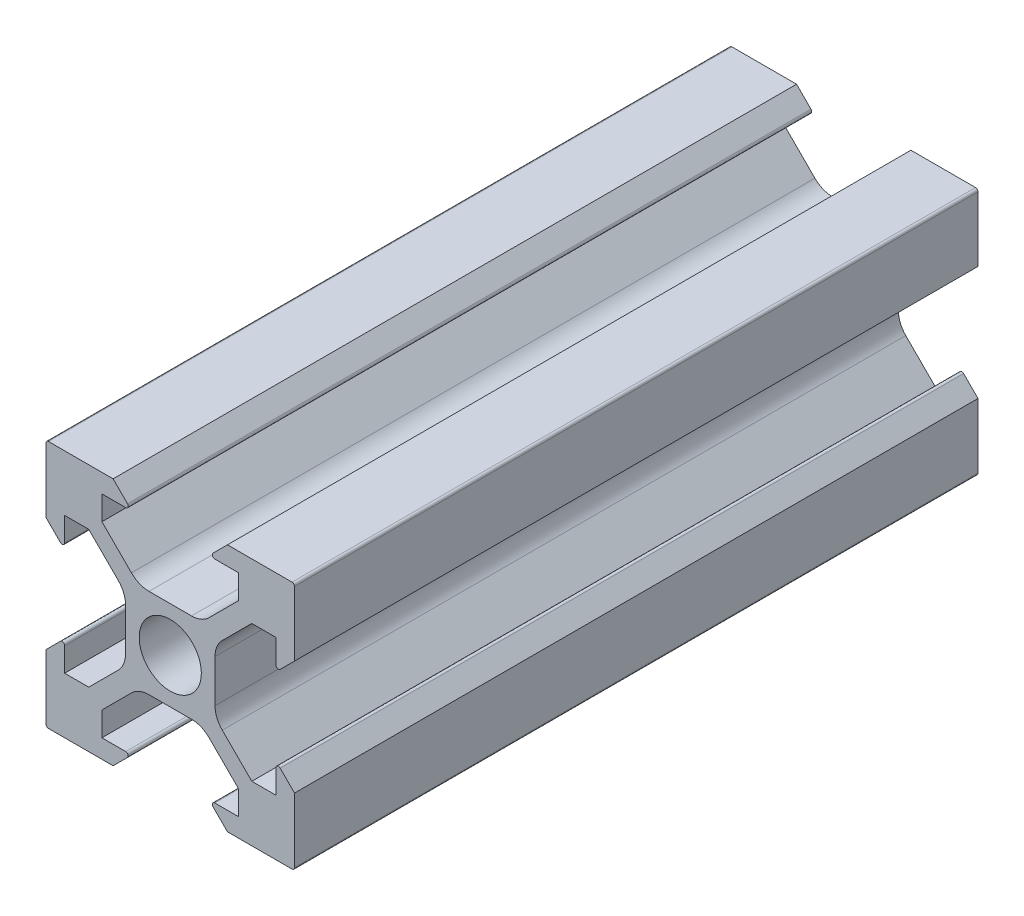
from build123d import *

# Parameters (mm, degrees)
ESBO_O1_R                = 2.5
RESSALTO_EXTRUS_O1_DEPTH = 55


with BuildPart() as part:
    # Esboço1 → Ressalto-extrusão1 (new body)
    with BuildSketch(Plane.XY):
        with BuildLine():
            Line((-4.6, -10), (-9.8, -10))
            ThreePointArc((-9.8, -10), (-9.941421356, -9.941421356), (-10, -9.8))
            Line((-10, -9.8), (-10, -4.6))
            Line((-10, -4.6), (-8.841421356, -3.441421356))
            ThreePointArc((-8.841421356, -3.441421356), (-8.623463314, -3.398066806), (-8.5, -3.582842712))
            Line((-8.5, -3.582842712), (-8.5, -5.5))
            Line((-8.5, -5.5), (-6.560660172, -5.5))
            Line((-6.560660172, -5.5), (-4.185786438, -3.125126266))
            ThreePointArc((-4.185786438, -3.125126266), (-3.752240935, -2.476279568), (-3.6, -1.710912703))
            Line((-3.6, -1.710912703), (-3.6, 1.710912703))
            ThreePointArc((-3.6, 1.710912703), (-3.752240935, 2.476279568), (-4.185786438, 3.125126266))
            Line((-4.185786438, 3.125126266), (-6.560660172, 5.5))
            Line((-6.560660172, 5.5), (-8.5, 5.5))
            Line((-8.5, 5.5), (-8.5, 3.582842712))
            ThreePointArc((-8.5, 3.582842712), (-8.623463314, 3.398066806), (-8.841421356, 3.441421356))
            Line((-8.841421356, 3.441421356), (-10, 4.6))
            Line((-10, 4.6), (-10, 9.8))
            ThreePointArc((-10, 9.8), (-9.941421356, 9.941421356), (-9.8, 10))
            Line((-9.8, 10), (-4.6, 10))
            Line((-4.6, 10), (-3.441421356, 8.841421356))
            ThreePointArc((-3.441421356, 8.841421356), (-3.398066806, 8.623463314), (-3.582842712, 8.5))
            Line((-3.582842712, 8.5), (-5.5, 8.5))
            Line((-5.5, 8.5), (-5.5, 6.560660172))
            Line((-5.5, 6.560660172), (-3.125126266, 4.185786438))
            ThreePointArc((-3.125126266, 4.185786438), (-2.476279568, 3.752240935), (-1.710912703, 3.6))
            Line((-1.710912703, 3.6), (1.710912703, 3.6))
            ThreePointArc((1.710912703, 3.6), (2.476279568, 3.752240935), (3.125126266, 4.185786438))
            Line((3.125126266, 4.185786438), (5.5, 6.560660172))
            Line((5.5, 6.560660172), (5.5, 8.5))
            Line((5.5, 8.5), (3.582842712, 8.5))
            ThreePointArc((3.582842712, 8.5), (3.398066806, 8.623463314), (3.441421356, 8.841421356))
            Line((3.441421356, 8.841421356), (4.6, 10))
            Line((4.6, 10), (9.8, 10))
            ThreePointArc((9.8, 10), (9.941421356, 9.941421356), (10, 9.8))
            Line((10, 9.8), (10, 4.6))
            Line((10, 4.6), (8.841421356, 3.441421356))
            ThreePointArc((8.841421356, 3.441421356), (8.623463314, 3.398066806), (8.5, 3.582842712))
            Line((8.5, 3.582842712), (8.5, 5.5))
            Line((8.5, 5.5), (6.560660172, 5.5))
            Line((6.560660172, 5.5), (4.185786438, 3.125126266))
            ThreePointArc((4.185786438, 3.125126266), (3.752240935, 2.476279568), (3.6, 1.710912703))
            Line((3.6, 1.710912703), (3.6, -1.710912703))
            ThreePointArc((3.6, -1.710912703), (3.752240935, -2.476279568), (4.185786438, -3.125126266))
            Line((4.185786438, -3.125126266), (6.560660172, -5.5))
            Line((6.560660172, -5.5), (8.5, -5.5))
            Line((8.5, -5.5), (8.5, -3.582842712))
            ThreePointArc((8.5, -3.582842712), (8.623463314, -3.398066806), (8.841421356, -3.441421356))
            Line((8.841421356, -3.441421356), (10, -4.6))
            Line((10, -4.6), (10, -9.8))
            ThreePointArc((10, -9.8), (9.941421356, -9.941421356), (9.8, -10))
            Line((9.8, -10), (4.6, -10))
            Line((4.6, -10), (3.441421356, -8.841421356))
            ThreePointArc((3.441421356, -8.841421356), (3.398066806, -8.623463314), (3.582842712, -8.5))
            Line((3.582842712, -8.5), (5.5, -8.5))
            Line((5.5, -8.5), (5.5, -6.560660172))
            Line((5.5, -6.560660172), (3.125126266, -4.185786438))
            ThreePointArc((3.125126266, -4.185786438), (2.476279568, -3.752240935), (1.710912703, -3.6))
            Line((1.710912703, -3.6), (-1.710912703, -3.6))
            ThreePointArc((-1.710912703, -3.6), (-2.476279568, -3.752240935), (-3.125126266, -4.185786438))
            Line((-3.125126266, -4.185786438), (-5.5, -6.560660172))
            Line((-5.5, -6.560660172), (-5.5, -8.5))
            Line((-5.5, -8.5), (-3.582842712, -8.5))
            ThreePointArc((-3.582842712, -8.5), (-3.398066806, -8.623463314), (-3.441421356, -8.841421356))
            Line((-3.441421356, -8.841421356), (-4.6, -10))
        make_face()
        Circle(ESBO_O1_R, mode=Mode.SUBTRACT)
    extrude(amount=RESSALTO_EXTRUS_O1_DEPTH)


solid = part.part
